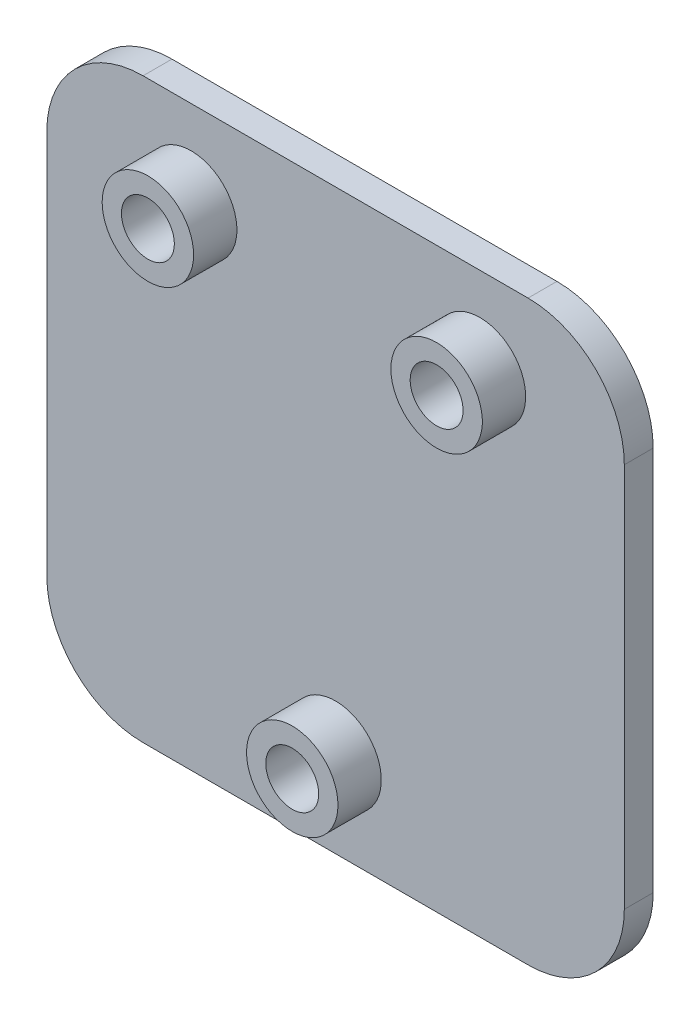
from build123d import *

# Parameters (mm, degrees)
SKETCH1_R           = 2.75
BOSS_EXTRUDE1_DEPTH = 3
SKETCH6_R           = 4.75
SKETCH6_R_2         = 2.75
BOSS_EXTRUDE3_DEPTH = 4.5


with BuildPart() as part:
    # Sketch1 → Boss-Extrude1 (new body)
    with BuildSketch(Plane.XY):
        with BuildLine():
            Line((-20, -30), (20, -30))
            ThreePointArc((20, -30), (27.071067812, -27.071067812), (30, -20))
            Line((30, -20), (30, 20))
            ThreePointArc((30, 20), (27.071067812, 27.071067812), (20, 30))
            Line((20, 30), (-20, 30))
            ThreePointArc((-20, 30), (-27.071067812, 27.071067812), (-30, 20))
            Line((-30, 20), (-30, -20))
            ThreePointArc((-30, -20), (-27.071067812, -27.071067812), (-20, -30))
        make_face()
        with Locations((-15, 21)):
            Circle(SKETCH1_R, mode=Mode.SUBTRACT)
        with Locations((0, -21)):
            Circle(SKETCH1_R, mode=Mode.SUBTRACT)
        with Locations((15, 21)):
            Circle(SKETCH1_R, mode=Mode.SUBTRACT)
    extrude(amount=BOSS_EXTRUDE1_DEPTH)

    # Sketch6 → Boss-Extrude3 (add)
    with BuildSketch(Plane.XY.offset(3)):
        with Locations((-15, 21)):
            Circle(SKETCH6_R)
        with Locations((-15, 21)):
            Circle(SKETCH6_R_2, mode=Mode.SUBTRACT)
        with Locations((0, -21)):
            Circle(SKETCH6_R)
        with Locations((0, -21)):
            Circle(SKETCH6_R_2, mode=Mode.SUBTRACT)
        with Locations((15, 21)):
            Circle(SKETCH6_R)
        with Locations((15, 21)):
            Circle(SKETCH6_R_2, mode=Mode.SUBTRACT)
    extrude(amount=BOSS_EXTRUDE3_DEPTH)


solid = part.part
